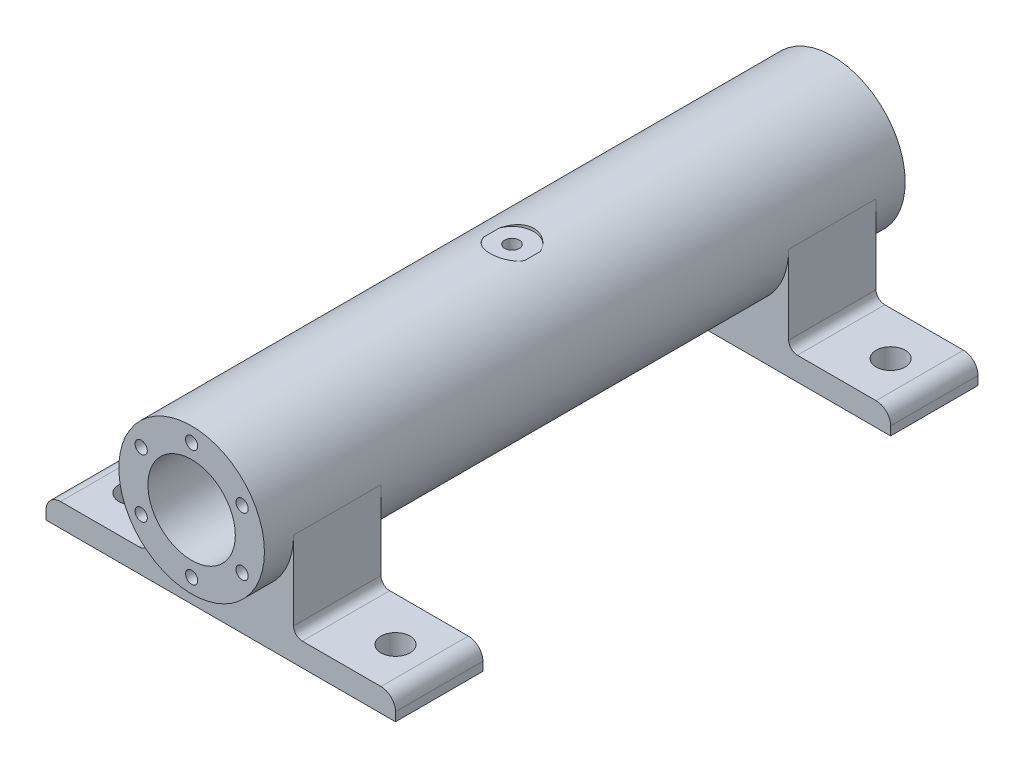
from build123d import *

# Parameters (mm, degrees)
SKETCH1_R                 = 25
SKETCH1_R_2               = 15
BOSS_EXTRUDE1_DEPTH       = 220
CIRPATTERN1_COUNT         = 6
SKETCH11_R                = 7.5
CUT_EXTRUDE2_DEPTH        = 1
SKETCH13_W                = 120
SKETCH13_H                = 30
BOSS_EXTRUDE3_DEPTH       = 38
SKETCH15_R                = 15
CUT_EXTRUDE3_DEPTH        = 221.0000001
SKETCH16_W                = 35
SKETCH16_H                = 30
CUT_EXTRUDE4_DEPTH        = 38
MIRROR4_COPY_1_SKETCH_W   = 35
MIRROR4_COPY_1_SKETCH_H   = 30
MIRROR4_COPY_1_DEPTH      = 38
FILLET1_R                 = 5
FILLET2_R                 = 3
M6X1_0_TAPPED_HOLE1_D     = 5
M6X1_0_TAPPED_HOLE1_DEPTH = 17
M6X1_0_TAPPED_HOLE1_TIP   = 1.502151548
LPATTERN1_COUNT           = 2
LPATTERN1_PITCH           = 90
LPATTERN1_COUNT_DIR2      = 2
LPATTERN1_PITCH_DIR2      = 170


with BuildPart() as part:
    # Sketch1 → Boss-Extrude1 (new body)
    with BuildSketch(Plane.XY):
        Circle(SKETCH1_R)
        Circle(SKETCH1_R_2, mode=Mode.SUBTRACT)
    extrude(amount=BOSS_EXTRUDE1_DEPTH)

    # Sketch2 → M5x0.8 Tapped Hole1 (revolve, cut)
    with BuildSketch(Plane(origin=(0, 20, 220), x_dir=(0, -1, 0), z_dir=(1, 0, 0))):
        Polygon((0, 0), (0, 15.2618073), (2.1, 14), (2.1, 0), align=None)
    m5x0_8_tapped_hole1 = revolve(axis=Axis((0, 20, 226.35), (0, 0, -1)), mode=Mode.SUBTRACT)

    # CirPattern1: M5x0.8 Tapped Hole1 ×6 about axis
    cirpattern1_axis = Axis((0, 0, 0), (0, 0, 1))
    for i in range(1, CIRPATTERN1_COUNT):
        add(m5x0_8_tapped_hole1.rotate(cirpattern1_axis, i * 360 / CIRPATTERN1_COUNT), mode=Mode.SUBTRACT)

    # Mirror1: M5x0.8 Tapped Hole1 across plane
    add(m5x0_8_tapped_hole1.mirror(Plane.XY.offset(110)), mode=Mode.SUBTRACT)

    # Mirror1 copy 1 sketch → Mirror1 copy 1 (revolve, cut)
    with BuildSketch(Plane(origin=(-17.320508076, 10, 0), x_dir=(0.866025404, -0.5, 0), z_dir=(0.5, 0.866025404, 0))):
        Polygon((0, 0), (0, -15.2618073), (2.1, -14), (2.1, 0), align=None)
    revolve(axis=Axis((-17.320508076, 10, -6.35), (0, 0, -1)), mode=Mode.SUBTRACT)

    # Mirror1 copy 2 sketch → Mirror1 copy 2 (revolve, cut)
    with BuildSketch(Plane(origin=(-17.320508076, -10, 0), x_dir=(0.866025404, 0.5, 0), z_dir=(-0.5, 0.866025404, 0))):
        Polygon((0, 0), (0, -15.2618073), (2.1, -14), (2.1, 0), align=None)
    revolve(axis=Axis((-17.320508076, -10, -6.35), (0, 0, -1)), mode=Mode.SUBTRACT)

    # Mirror1 copy 3 sketch → Mirror1 copy 3 (revolve, cut)
    with BuildSketch(Plane(origin=(0, -20, 0), x_dir=(0, 1, 0), z_dir=(-1, 0, 0))):
        Polygon((0, 0), (0, -15.2618073), (2.1, -14), (2.1, 0), align=None)
    revolve(axis=Axis((0, -20, -6.35), (0, 0, -1)), mode=Mode.SUBTRACT)

    # Mirror1 copy 4 sketch → Mirror1 copy 4 (revolve, cut)
    with BuildSketch(Plane(origin=(17.320508076, -10, 0), x_dir=(-0.866025404, 0.5, 0), z_dir=(-0.5, -0.866025404, 0))):
        Polygon((0, 0), (0, -15.2618073), (2.1, -14), (2.1, 0), align=None)
    revolve(axis=Axis((17.320508076, -10, -6.35), (0, 0, -1)), mode=Mode.SUBTRACT)

    # Mirror1 copy 5 sketch → Mirror1 copy 5 (revolve, cut)
    with BuildSketch(Plane(origin=(17.320508076, 10, 0), x_dir=(-0.866025404, -0.5, 0), z_dir=(0.5, -0.866025404, 0))):
        Polygon((0, 0), (0, -15.2618073), (2.1, -14), (2.1, 0), align=None)
    revolve(axis=Axis((17.320508076, 10, -6.35), (0, 0, -1)), mode=Mode.SUBTRACT)

    # Sketch11 → Cut-Extrude2 (cut)
    with BuildSketch(Plane(origin=(0, 25, 0), x_dir=(-1, 0, 0), z_dir=(0, 1, 0))):
        with Locations((0, 110)):
            Circle(SKETCH11_R)
    extrude(amount=-CUT_EXTRUDE2_DEPTH, mode=Mode.SUBTRACT)

    # Sketch13 → Boss-Extrude3 (add)
    with BuildSketch(Plane(origin=(0, 0, 0), x_dir=(1, 0, 0), z_dir=(0, 1, 0))):
        with Locations((0, -195)):
            Rectangle(SKETCH13_W, SKETCH13_H)
    boss_extrude3 = extrude(amount=-BOSS_EXTRUDE3_DEPTH)

    # Mirror2: Boss-Extrude3 across plane
    add(boss_extrude3.mirror(Plane.XY.offset(110)))

    # Sketch15 → Cut-Extrude3 (cut, through all)
    with BuildSketch(Plane.XY.offset(220)):
        Circle(SKETCH15_R)
    extrude(amount=-CUT_EXTRUDE3_DEPTH, mode=Mode.SUBTRACT)

    # Sketch16 → Cut-Extrude4 (cut)
    with BuildSketch(Plane.XY.offset(210)):
        with Locations((-42.5, -15)):
            Rectangle(SKETCH16_W, SKETCH16_H)
    cut_extrude4 = extrude(amount=-CUT_EXTRUDE4_DEPTH, mode=Mode.SUBTRACT)

    # Mirror3: Cut-Extrude4 across plane
    add(cut_extrude4.mirror(Plane(origin=(0, 0, 0), x_dir=(0, 0, 1), z_dir=(1, 0, 0))), mode=Mode.SUBTRACT)

    # Mirror4: Cut-Extrude4 across plane
    add(cut_extrude4.mirror(Plane.XY.offset(110)), mode=Mode.SUBTRACT)

    # Mirror4 copy 1 sketch → Mirror4 copy 1 (cut)
    with BuildSketch(Plane(origin=(0, 0, 10), x_dir=(-1, 0, 0), z_dir=(0, 0, -1))):
        with Locations((-42.5, -15)):
            Rectangle(MIRROR4_COPY_1_SKETCH_W, MIRROR4_COPY_1_SKETCH_H)
    extrude(amount=-MIRROR4_COPY_1_DEPTH, mode=Mode.SUBTRACT)

    # Fillet1
    fillet1_edges = [part.edges().sort_by_distance(p)[0] for p in [
        (-60, -30, 195),
        (60, -30, 195),
        (60, -30, 25),
        (-60, -30, 25),
    ]]
    fillet(fillet1_edges, radius=FILLET1_R)

    # Fillet2
    fillet2_edges = [part.edges().sort_by_distance(p)[0] for p in [
        (-25, -30, 195),
        (25, -30, 195),
        (25, -30, 25),
        (-25, -30, 25),
    ]]
    fillet(fillet2_edges, radius=FILLET2_R)

    # Sketch19 → Ø10.0 (10) Diameter Hole1 (revolve, cut)
    with BuildSketch(Plane(origin=(-45, -30, 25), x_dir=(0, 0, 1), z_dir=(1, 0, 0))):
        Polygon((0, 0), (0, 14.004303095), (5, 11), (5, 0), align=None)
    f_10_0_10_diameter_hole1 = revolve(axis=Axis((-45, -23.65, 25), (0, -1, 0)), mode=Mode.SUBTRACT)

    # M6x1.0 Tapped Hole1
    with Locations(Plane(origin=(0, 24, 0), x_dir=(-1, 0, 0), z_dir=(0, 1, 0))):
        with Locations((0, 110)):
            Hole(M6X1_0_TAPPED_HOLE1_D / 2, depth=M6X1_0_TAPPED_HOLE1_DEPTH)
            with Locations((0, 0, -(M6X1_0_TAPPED_HOLE1_DEPTH + M6X1_0_TAPPED_HOLE1_TIP / 2))):  # 118° drill point
                Cone(0, M6X1_0_TAPPED_HOLE1_D / 2, M6X1_0_TAPPED_HOLE1_TIP, mode=Mode.SUBTRACT)

    # LPattern1: 10.0 _10_ Diameter Hole1 2 × 2
    with Locations(*[(i * LPATTERN1_PITCH, 0, j * LPATTERN1_PITCH_DIR2) for i in range(LPATTERN1_COUNT) for j in range(LPATTERN1_COUNT_DIR2) if (i, j) != (0, 0)]):
        add(f_10_0_10_diameter_hole1, mode=Mode.SUBTRACT)


solid = part.part
